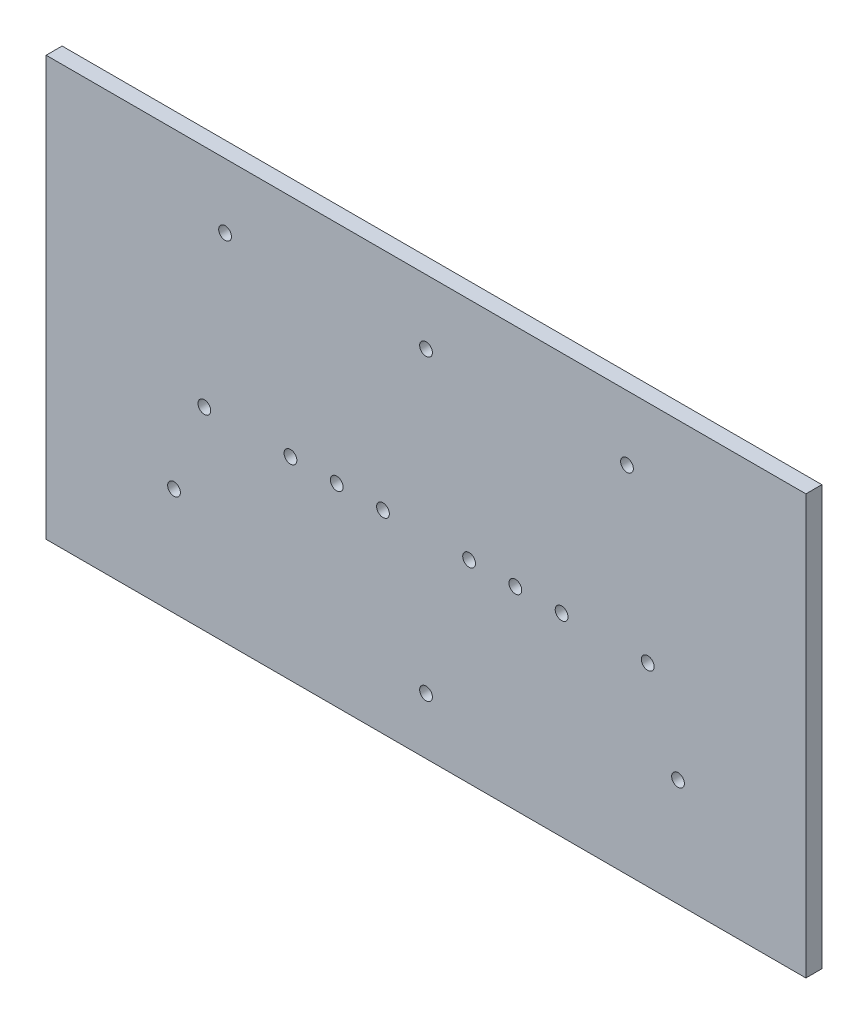
from build123d import *

# Parameters (mm, degrees)
SKETCH_2_W          = 238.179152398
SKETCH_2_H          = 131.442897672
SKETCH_2_R          = 2
EXTRUDE_1_DEPTH     = 5
CUT_EXTRUDE_1_DEPTH = 1


with BuildPart() as part:
    # 草图2 → 凸台-拉伸1 (new body)
    with BuildSketch(Plane.XY):
        Rectangle(SKETCH_2_W, SKETCH_2_H)
        with Locations((13.5, -5)):
            Circle(SKETCH_2_R, mode=Mode.SUBTRACT)
        with Locations((28, -5)):
            Circle(SKETCH_2_R, mode=Mode.SUBTRACT)
        with Locations((42.5, -5)):
            Circle(SKETCH_2_R, mode=Mode.SUBTRACT)
        with Locations((79, -32)):
            Circle(SKETCH_2_R, mode=Mode.SUBTRACT)
        with Locations((69.5, -5)):
            Circle(SKETCH_2_R, mode=Mode.SUBTRACT)
        with Locations((-63, 45.5)):
            Circle(SKETCH_2_R, mode=Mode.SUBTRACT)
        with Locations((0, 45.5)):
            Circle(SKETCH_2_R, mode=Mode.SUBTRACT)
        with Locations((63, 45.5)):
            Circle(SKETCH_2_R, mode=Mode.SUBTRACT)
        with Locations((-79, -32)):
            Circle(SKETCH_2_R, mode=Mode.SUBTRACT)
        with Locations((-69.5, -5)):
            Circle(SKETCH_2_R, mode=Mode.SUBTRACT)
        with Locations((-42.5, -5)):
            Circle(SKETCH_2_R, mode=Mode.SUBTRACT)
        with Locations((-28, -5)):
            Circle(SKETCH_2_R, mode=Mode.SUBTRACT)
        with Locations((-13.5, -5)):
            Circle(SKETCH_2_R, mode=Mode.SUBTRACT)
        with Locations((0, -48)):
            Circle(SKETCH_2_R, mode=Mode.SUBTRACT)
    extrude(amount=EXTRUDE_1_DEPTH)

    # 草图2<3> → 切除-拉伸1 (cut)
    with BuildSketch(Plane.XY):
        with BuildLine():
            Line((-69, -57), (69, -57))
            ThreePointArc((69, -57), (84.556349186, -50.556349186), (91, -35))
            Line((91, -35), (91, 35))
            ThreePointArc((91, 35), (84.556349186, 50.556349186), (69, 57))
            Line((69, 57), (-69, 57))
            ThreePointArc((-69, 57), (-84.556349186, 50.556349186), (-91, 35))
            Line((-91, 35), (-91, -35))
            ThreePointArc((-91, -35), (-84.556349186, -50.556349186), (-69, -57))
        make_face()
        with BuildLine():
            Line((-69, 55), (69, 55))
            ThreePointArc((69, 55), (83.142135624, 49.142135624), (89, 35))
            Line((89, 35), (89, -35))
            ThreePointArc((89, -35), (83.142135624, -49.142135624), (69, -55))
            Line((69, -55), (-69, -55))
            ThreePointArc((-69, -55), (-83.142135624, -49.142135624), (-89, -35))
            Line((-89, -35), (-89, 35))
            ThreePointArc((-89, 35), (-83.142135624, 49.142135624), (-69, 55))
        make_face(mode=Mode.SUBTRACT)
    extrude(amount=CUT_EXTRUDE_1_DEPTH, mode=Mode.SUBTRACT)


solid = part.part
